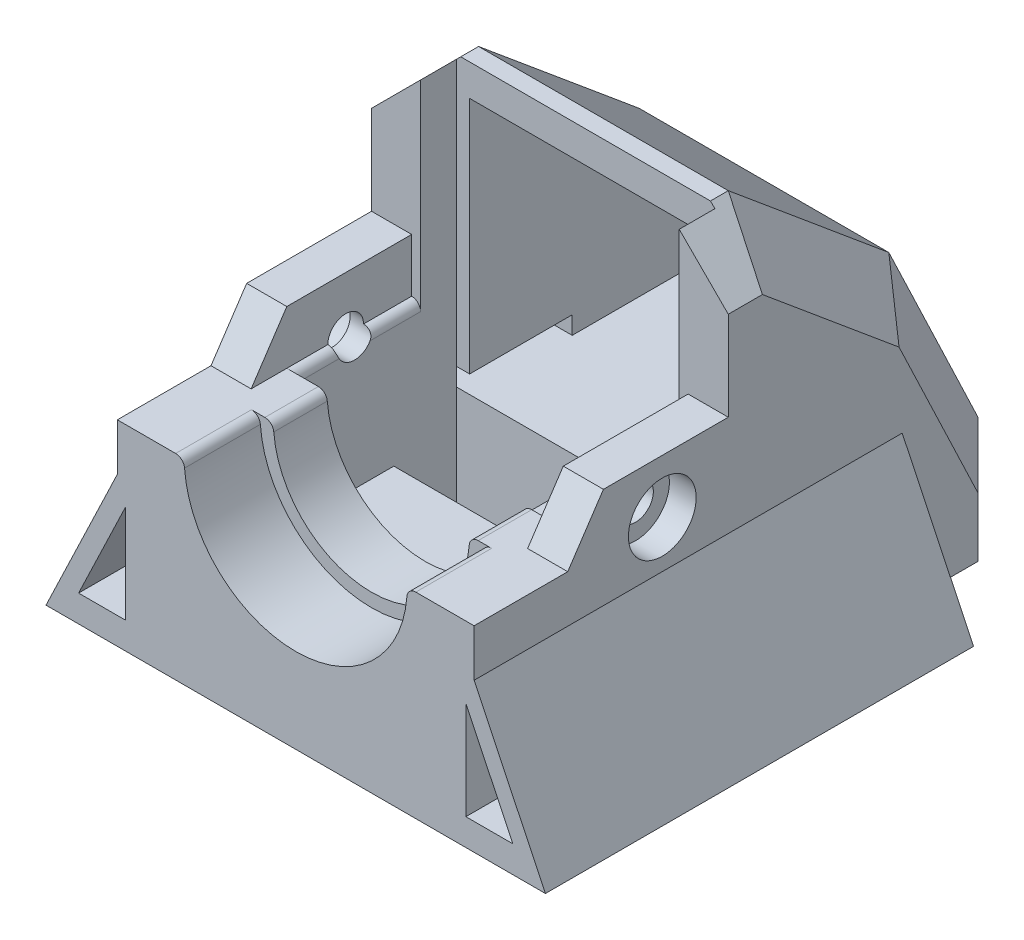
from build123d import *

# Parameters (mm, degrees)
SKIZZE1_W                             = 20
SKIZZE1_H                             = 22
AUFSATZ_LINEAR_AUSTRAGEN1_DEPTH       = 35
SKIZZE2_R                             = 5.5
SCHNITT_LINEAR_AUSTRAGEN1_DEPTH       = 11
SKIZZE3_R                             = 6.25
SCHNITT_LINEAR_AUSTRAGEN2_DEPTH       = 8
SKIZZE5_W                             = 14.5
SKIZZE5_H                             = 18.25
SCHNITT_LINEAR_AUSTRAGEN3_DEPTH       = 9
SKIZZE13_W                            = 20
SKIZZE13_H                            = 11
SCHNITT_LINEAR_AUSTRAGEN6_DEPTH       = 18
SCHNITT_LINEAR_AUSTRAGEN7_DEPTH       = 46.923850013
VERRUNDUNG1_R                         = 0.5
FASE1_SIZE                            = 3
FASE2_SIZE                            = 3
FASE3_SIZE                            = 3
FASE4_SIZE                            = 1.5
SKIZZE17_W                            = 6
SKIZZE17_H                            = 3.5
SCHNITT_LINEAR_AUSTRAGEN8_DEPTH       = 45.25
SCHNITT_LINEAR_AUSTRAGEN9_REACH       = 47.924
SKIZZE18_W                            = 3.75
SKIZZE18_H                            = 11
SCHNITT_LINEAR_AUSTRAGEN10_DEPTH      = 6.5
SCHNITT_LINEAR_AUSTRAGEN10_DEPTH_BACK = 6.5
AUFSATZ_LINEAR_AUSTRAGEN2_DEPTH       = 24
SCHNITT_LINEAR_AUSTRAGEN11_DEPTH      = 22
SKIZZE26_W                            = 5.75
SKIZZE26_H                            = 1
SCHNITT_LINEAR_AUSTRAGEN12_DEPTH      = 4
AUFSATZ_LINEAR_AUSTRAGEN3_DEPTH       = 14.25
SKIZZE28_W                            = 2.25
SKIZZE28_H                            = 3
AUFSATZ_LINEAR_AUSTRAGEN4_DEPTH       = 7
AUFSATZ_LINEAR_AUSTRAGEN6_DEPTH       = 2.25
SCHNITT_LINEAR_AUSTRAGEN13_REACH      = 47.128
SKIZZE32_R                            = 1
SCHNITT_LINEAR_START                  = 10
SKIZZE33_R                            = 1.9
SCHNITT_LINEAR_AUSTRAGEN14_DEPTH      = 1.5
SKIZZE34_R                            = 1.9
SCHNITT_LINEAR_AUSTRAGEN15_DEPTH      = 1.5


with BuildPart() as part:
    # Skizze1 → Aufsatz-Linear austragen1 (new body)
    with BuildSketch(Plane.XY):
        with Locations((10, 11)):
            Rectangle(SKIZZE1_W, SKIZZE1_H)
    extrude(amount=AUFSATZ_LINEAR_AUSTRAGEN1_DEPTH)

    # Skizze2 → Schnitt-Linear austragen1 (cut)
    with BuildSketch(Plane.XY.offset(35)):
        with Locations((10, 11)):
            Circle(SKIZZE2_R)
    extrude(amount=-SCHNITT_LINEAR_AUSTRAGEN1_DEPTH, mode=Mode.SUBTRACT)

    # Skizze3 → Schnitt-Linear austragen2 (cut)
    with BuildSketch(Plane.XY.offset(35)):
        with Locations((10, 11)):
            Circle(SKIZZE3_R)
    extrude(amount=-SCHNITT_LINEAR_AUSTRAGEN2_DEPTH, mode=Mode.SUBTRACT)

    # Skizze5 → Schnitt-Linear austragen3 (cut)
    with BuildSketch(Plane.XY.offset(24)):
        with Locations((10, 12.875)):
            Rectangle(SKIZZE5_W, SKIZZE5_H)
    extrude(amount=-SCHNITT_LINEAR_AUSTRAGEN3_DEPTH, mode=Mode.SUBTRACT)

    # Skizze13 → Schnitt-Linear austragen6 (cut)
    with BuildSketch(Plane.XY.offset(35)):
        with Locations((10, 16.5)):
            Rectangle(SKIZZE13_W, SKIZZE13_H)
    extrude(amount=-SCHNITT_LINEAR_AUSTRAGEN6_DEPTH, mode=Mode.SUBTRACT)

    # Skizze16 → Schnitt-Linear austragen7 (cut, through all)
    with BuildSketch(Plane.ZY):
        Polygon((14, 22), (5, 14.5), (0, 4), (0, 22), align=None)
    extrude(amount=-SCHNITT_LINEAR_AUSTRAGEN7_DEPTH, mode=Mode.SUBTRACT)

    # Verrundung1
    verrundung1_edges = [part.edges().sort_by_distance(p)[0] for p in [
        (17.25, 11, 20.5),
        (3.75, 11, 31),
        (2.75, 11, 20.5),
        (4.5, 11, 25.5),
        (16.25, 11, 31),
        (15.5, 11, 25.5),
    ]]
    fillet(verrundung1_edges, radius=VERRUNDUNG1_R)

    # Fase1
    fase1_edges = [part.edges().sort_by_distance(p)[0] for p in [
        (20, 22, 15.5),
        (0, 22, 15.5),
    ]]
    chamfer(fase1_edges, length=FASE1_SIZE)

    # Fase2
    fase2_edges = [part.edges().sort_by_distance(p)[0] for p in [
        (0, 16.75, 7.7),
        (20, 16.75, 7.7),
    ]]
    chamfer(fase2_edges, length=FASE2_SIZE)

    # Fase3
    fase3_edges = [part.edges().sort_by_distance(p)[0] for p in [
        (20, 6.012857042, 0.958503353),
        (20, 2, 0),
        (0, 6.012857042, 0.958503353),
        (0, 2, 0),
    ]]
    chamfer(fase3_edges, length=FASE3_SIZE)

    # Fase4
    fase4_edges = [part.edges().sort_by_distance(p)[0] for p in [
        (20, 11, 26),
        (0, 11, 26),
    ]]
    chamfer(fase4_edges, length=FASE4_SIZE)

    # Skizze17 → Schnitt-Linear austragen8 (cut, through all)
    with BuildSketch(Plane(origin=(0, 3.75, 0), x_dir=(1, 0, 0), z_dir=(0, 1, 0))):
        with Locations((5.75, -16.75)):
            Rectangle(SKIZZE17_W, SKIZZE17_H)
    extrude(amount=-SCHNITT_LINEAR_AUSTRAGEN8_DEPTH, mode=Mode.SUBTRACT)

    # Schnitt-Linear austragen9: up to this face of the body (flat: up to its plane)
    schnitt_linear_austragen9_end = Plane(part.part.faces().sort_by_distance((20, 6.280299508, 18.20769637))[0])
    # Skizze18 → Schnitt-Linear austragen9 (cut, up to the picked face)
    with BuildSketch(Plane.ZY, mode=Mode.PRIVATE) as schnitt_linear_austragen9_sk1:
        with Locations((33.125, 5.5)):
            Rectangle(SKIZZE18_W, SKIZZE18_H)
    schnitt_linear_austragen9_tool1 = split(extrude(schnitt_linear_austragen9_sk1.sketch, amount=-SCHNITT_LINEAR_AUSTRAGEN9_REACH, mode=Mode.PRIVATE), bisect_by=schnitt_linear_austragen9_end, keep=Keep.BOTH, mode=Mode.PRIVATE)
    add(schnitt_linear_austragen9_tool1.solids().sort_by(Axis((0, 5.5, 33.125), (1, 0, 0)))[0], mode=Mode.SUBTRACT)

    # Skizze22 → Schnitt-Linear austragen10 (cut, two sides)
    with BuildSketch(Plane.ZY.offset(-10)) as schnitt_linear_austragen10_sk:
        Polygon((15, 20.229916775), (6.617209038, 13.24425764), (5.760028677, 11.896060222), (3.760028677, 11.896060222), (0.88063989, 5.849343769), (6.035195751, 5.849343769), (15, 5.849343769), align=None)
    extrude(amount=SCHNITT_LINEAR_AUSTRAGEN10_DEPTH, mode=Mode.SUBTRACT)
    extrude(schnitt_linear_austragen10_sk.sketch, amount=-SCHNITT_LINEAR_AUSTRAGEN10_DEPTH_BACK, mode=Mode.SUBTRACT)

    # Skizze23 → Aufsatz-Linear austragen2 (add)
    with BuildSketch(Plane.XY.offset(31.25)):
        Polygon((0, 8.353013166), (-4, 0), (0, 0), align=None)
    aufsatz_linear_austragen2 = extrude(amount=-AUFSATZ_LINEAR_AUSTRAGEN2_DEPTH)

    # Spiegeln1: Aufsatz-Linear austragen2 across plane
    add(aufsatz_linear_austragen2.mirror(Plane.ZY.offset(-10)))

    # Skizze24 → Schnitt-Linear austragen11 (cut)
    with BuildSketch(Plane.XY.offset(31.25)):
        Polygon((0.460828855, 1.5), (-2.172951263, 1.5), (0.460828855, 7), align=None)
    schnitt_linear_austragen11 = extrude(amount=-SCHNITT_LINEAR_AUSTRAGEN11_DEPTH, mode=Mode.SUBTRACT)

    # Skizze26 → Schnitt-Linear austragen12 (cut)
    with BuildSketch(Plane.ZY.offset(-16.5)):
        with Locations((12.125, 6.349343769)):
            Rectangle(SKIZZE26_W, SKIZZE26_H)
    schnitt_linear_austragen12 = extrude(amount=-SCHNITT_LINEAR_AUSTRAGEN12_DEPTH, mode=Mode.SUBTRACT)

    # Spiegeln2: Schnitt-Linear austragen12 across plane
    add(schnitt_linear_austragen12.mirror(Plane.ZY.offset(-10)), mode=Mode.SUBTRACT)

    # Spiegeln3: Schnitt-Linear austragen11 across plane
    add(schnitt_linear_austragen11.mirror(Plane.ZY.offset(-10)), mode=Mode.SUBTRACT)

    # Skizze27 → Aufsatz-Linear austragen3 (add)
    with BuildSketch(Plane.XY.offset(17)):
        Polygon((0, 9.5), (1.5, 11), (0, 11), align=None)
    aufsatz_linear_austragen3 = extrude(amount=AUFSATZ_LINEAR_AUSTRAGEN3_DEPTH)

    # Spiegeln4: Aufsatz-Linear austragen3 across plane
    add(aufsatz_linear_austragen3.mirror(Plane.ZY.offset(-10)))

    # Skizze28 → Aufsatz-Linear austragen4 (add)
    with BuildSketch(Plane.XY.offset(17)):
        with Locations((1.125, 12.5)):
            Rectangle(SKIZZE28_W, SKIZZE28_H)
    aufsatz_linear_austragen4 = extrude(amount=AUFSATZ_LINEAR_AUSTRAGEN4_DEPTH)

    # Skizze31 → Aufsatz-Linear austragen6 (add)
    with BuildSketch(Plane.ZY):
        Polygon((24, 14), (26, 11), (24, 11), align=None)
    aufsatz_linear_austragen6 = extrude(amount=-AUFSATZ_LINEAR_AUSTRAGEN6_DEPTH)

    # Schnitt-Linear austragen13: up to this face of the body (flat: up to its plane)
    schnitt_linear_austragen13_end = Plane(part.part.faces().sort_by_distance((2.75, 8.51118677, 18.308365759))[0])
    # Skizze32 → Schnitt-Linear austragen13 (cut, up to the picked face)
    with BuildSketch(Plane.ZY, mode=Mode.PRIVATE) as schnitt_linear_austragen13_sk1:
        with Locations((20.7, 11)):
            Circle(SKIZZE32_R)
    schnitt_linear_austragen13_tool1 = split(extrude(schnitt_linear_austragen13_sk1.sketch, amount=-SCHNITT_LINEAR_AUSTRAGEN13_REACH, mode=Mode.PRIVATE), bisect_by=schnitt_linear_austragen13_end, keep=Keep.BOTH, mode=Mode.PRIVATE)
    schnitt_linear_austragen13 = schnitt_linear_austragen13_tool1.solids().sort_by(Axis((0, 11, 20.7), (1, 0, 0)))[0]
    add(schnitt_linear_austragen13, mode=Mode.SUBTRACT)

    # Skizze33 → Schnitt-Linear austragen14 (cut)
    with BuildSketch(Plane.ZY.offset(-10).offset(SCHNITT_LINEAR_START)):
        with Locations(Location((20.7, 11, 0), (0, 0, 180))):
            Circle(SKIZZE33_R)
    extrude(amount=-SCHNITT_LINEAR_AUSTRAGEN14_DEPTH, mode=Mode.SUBTRACT)

    # Spiegeln6: Aufsatz-Linear austragen4, Aufsatz-Linear austragen6 across plane
    add(aufsatz_linear_austragen4.mirror(Plane.ZY.offset(-10)))
    add(aufsatz_linear_austragen6.mirror(Plane.ZY.offset(-10)))

    # Spiegeln8: Schnitt-Linear austragen13 across plane
    add(schnitt_linear_austragen13.mirror(Plane.ZY.offset(-10)), mode=Mode.SUBTRACT)

    # Skizze34 → Schnitt-Linear austragen15 (cut)
    with BuildSketch(Plane(origin=(20, 0, 0), x_dir=(0, 0, -1), z_dir=(1, 0, 0))):
        with Locations((-20.7, 11)):
            Circle(SKIZZE34_R)
    extrude(amount=-SCHNITT_LINEAR_AUSTRAGEN15_DEPTH, mode=Mode.SUBTRACT)


solid = part.part
